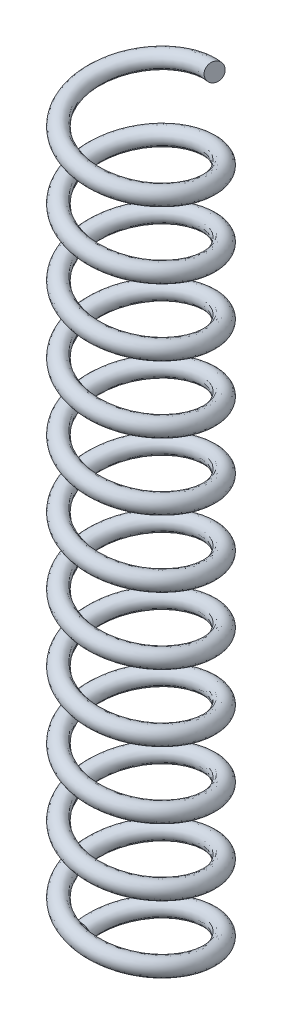
from build123d import *

# Parameters (mm, degrees)
SWEEP1_PITCH       = 2
SWEEP1_HEIGHT      = 22.6
SWEEP1_RADIUS      = 1.75
SWEEP1_START_ANGLE = -90
SWEEP1_PROFILE_R   = 0.25


with BuildPart() as part:
    # Sweep1: sweep along a helix
    with BuildLine() as sweep1_path:
        add(Helix(SWEEP1_PITCH, SWEEP1_HEIGHT, SWEEP1_RADIUS, center=(0, 0, 0), direction=(0, 1, 0), lefthand=True, mode=Mode.PRIVATE).rotate(Axis((0, 0, 0), (0, 1, 0)), SWEEP1_START_ANGLE))
    # Sweep1 profile (on start of the path) → Sweep1 (sweep)
    with BuildSketch(Plane(origin=(-1.75, 0, 0), x_dir=(0, -0.983857236, -0.178955134), z_dir=(0, 0.178955134, -0.983857236))):
        Circle(SWEEP1_PROFILE_R)
    sweep(path=sweep1_path.line, is_frenet=True)


solid = part.part
